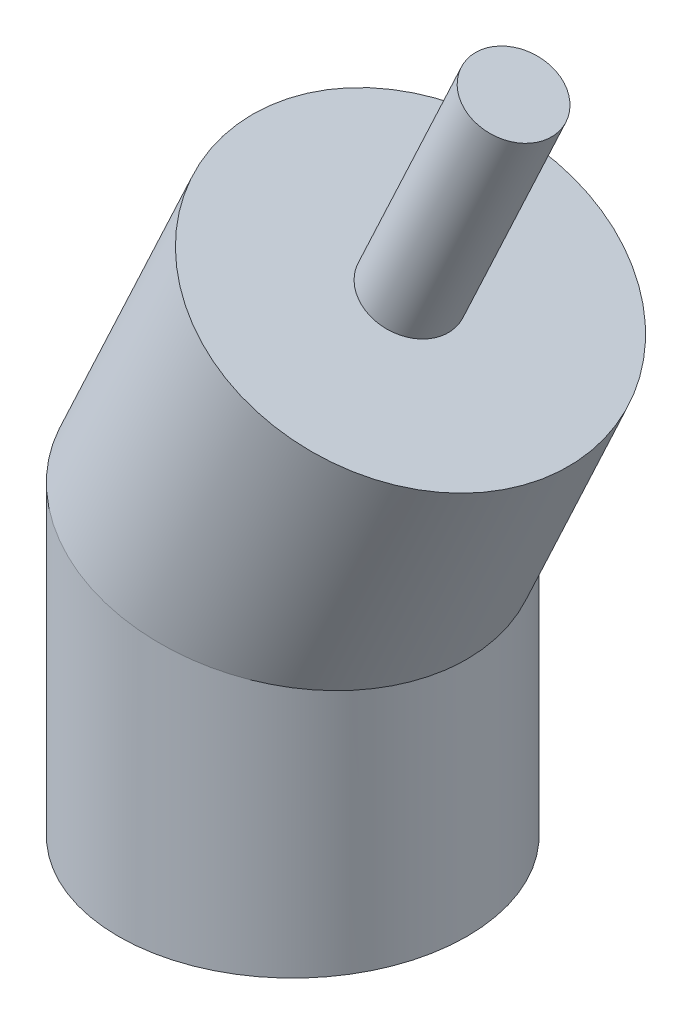
from build123d import *

# Parameters (mm, degrees)
ESBO_O2_R                = 25
ESBO_O3_R                = 6
RESSALTO_EXTRUS_O1_DEPTH = 35
ESBO_O4_R                = 6
CORTE_EXTRUS_O1_DEPTH    = 20


with BuildPart() as part:
    # Varredura1: sweep along a path in Esboço1
    with BuildLine(Plane.XY) as varredura1_path:
        Line((16.90473047, 76.252311481), (0, 40))
        Line((0, 40), (0, 0))
    # Esboço2 → Varredura1 (sweep)
    with BuildSketch(Plane(origin=(0, 0, 0), x_dir=(1, 0, 0), z_dir=(0, 1, 0))):
        Circle(ESBO_O2_R)
    sweep(path=varredura1_path.line, transition=Transition.RIGHT)

    # Esboço3 → Ressalto-extrusão1 (add)
    with BuildSketch(Plane(origin=(32.225619332, 69.108063675, 0), x_dir=(0.906307787, -0.422618262, 0), z_dir=(0.422618262, 0.906307787, 0))):
        with Locations((-16.90473047, 0)):
            Circle(ESBO_O3_R)
    extrude(amount=RESSALTO_EXTRUS_O1_DEPTH)

    # Esboço4 → Corte-extrusão1 (cut)
    with BuildSketch(Plane.XZ):
        Circle(ESBO_O4_R)
    extrude(amount=-CORTE_EXTRUS_O1_DEPTH, mode=Mode.SUBTRACT)


solid = part.part
